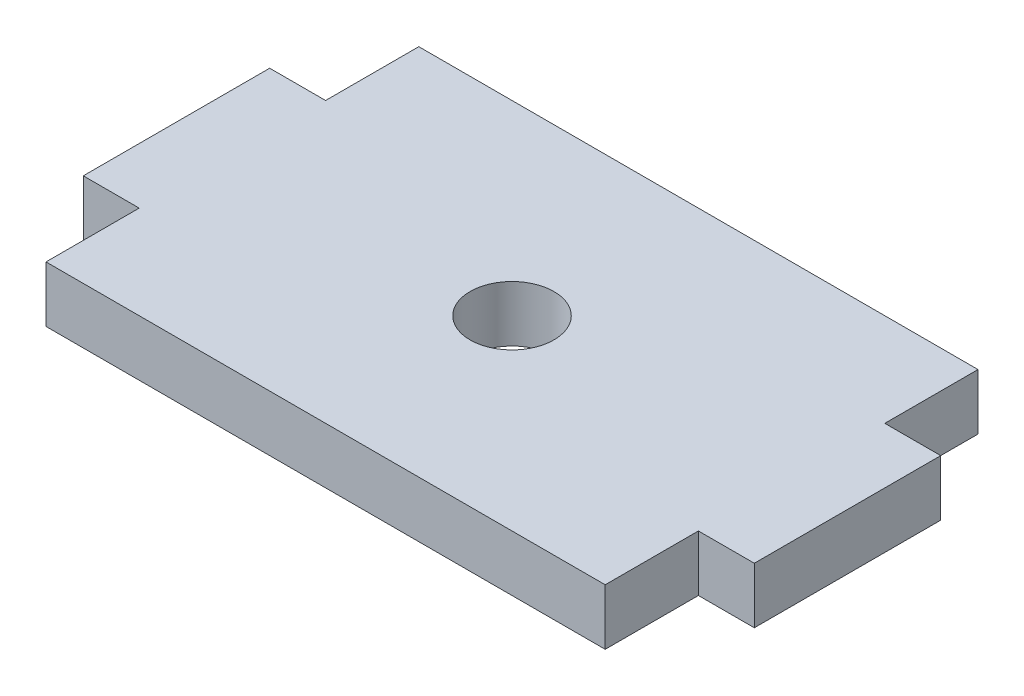
from build123d import *

# Parameters (mm, degrees)
SKETCH1_R           = 2.25
BOSS_EXTRUDE1_DEPTH = 3


with BuildPart() as part:
    # Sketch1 → Boss-Extrude1 (new body)
    with BuildSketch(Plane(origin=(0, 0, 0), x_dir=(1, 0, 0), z_dir=(0, 1, 0))):
        Polygon((-15, 10), (-15, 5), (-18, 5), (-18, -5), (-15, -5), (-15, -10), (15, -10), (15, -5), (18, -5), (18, 5), (15, 5), (15, 10), align=None)
        Circle(SKETCH1_R, mode=Mode.SUBTRACT)
    extrude(amount=BOSS_EXTRUDE1_DEPTH)


solid = part.part
